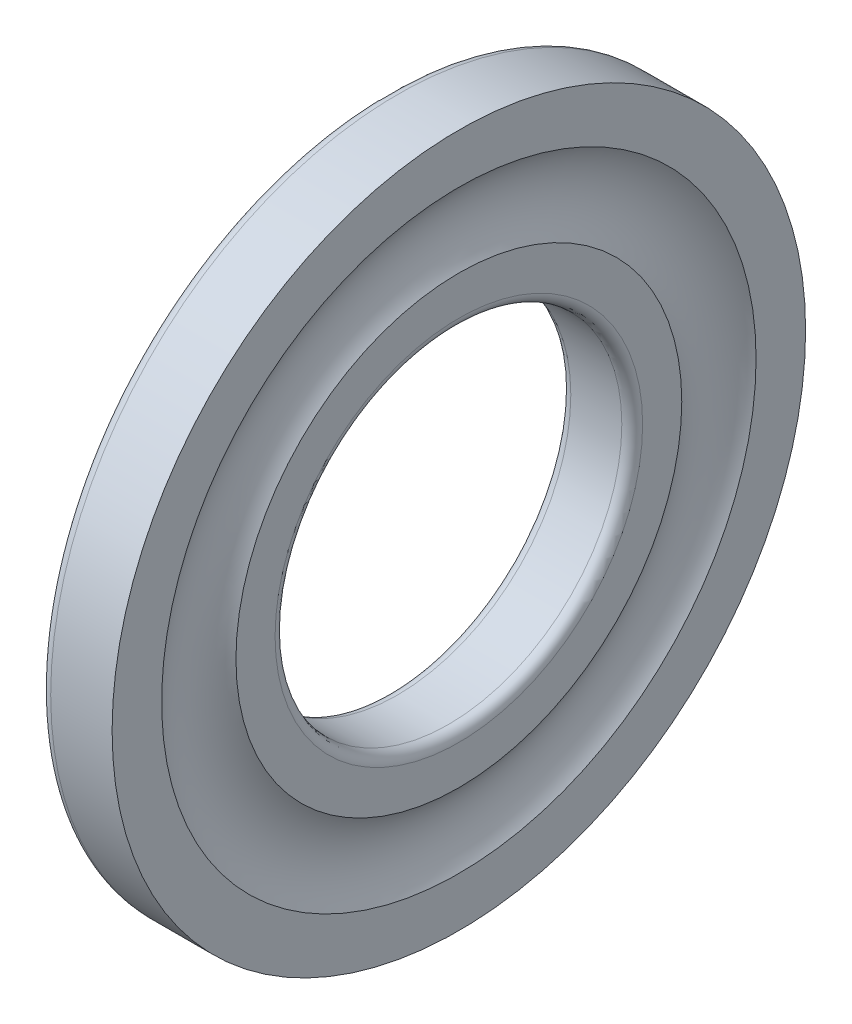
from build123d import *


with BuildPart() as part:
    # Croquis1 → Revolución1 (revolve)
    with BuildSketch(Plane.XY):
        with BuildLine():
            Line((0.6, 10), (3.542, 10))
            ThreePointArc((3.542, 10), (3.966264069, 10.175735931), (4.142, 10.6))
            Line((4.142, 10.6), (4.142, 12.857333437))
            ThreePointArc((4.142, 12.857333437), (3.428, 15), (4.142, 17.142666563))
            Line((4.142, 17.142666563), (4.142, 20))
            Line((4.142, 20), (0.6, 20))
            ThreePointArc((0.6, 20), (0.175735931, 19.824264069), (0, 19.4))
            Line((0, 19.4), (0, 10.6))
            ThreePointArc((0, 10.6), (0.175735931, 10.175735931), (0.6, 10))
        make_face()
    revolve(axis=Axis((3.542, 0, 0), (-1, 0, 0)))


solid = part.part
